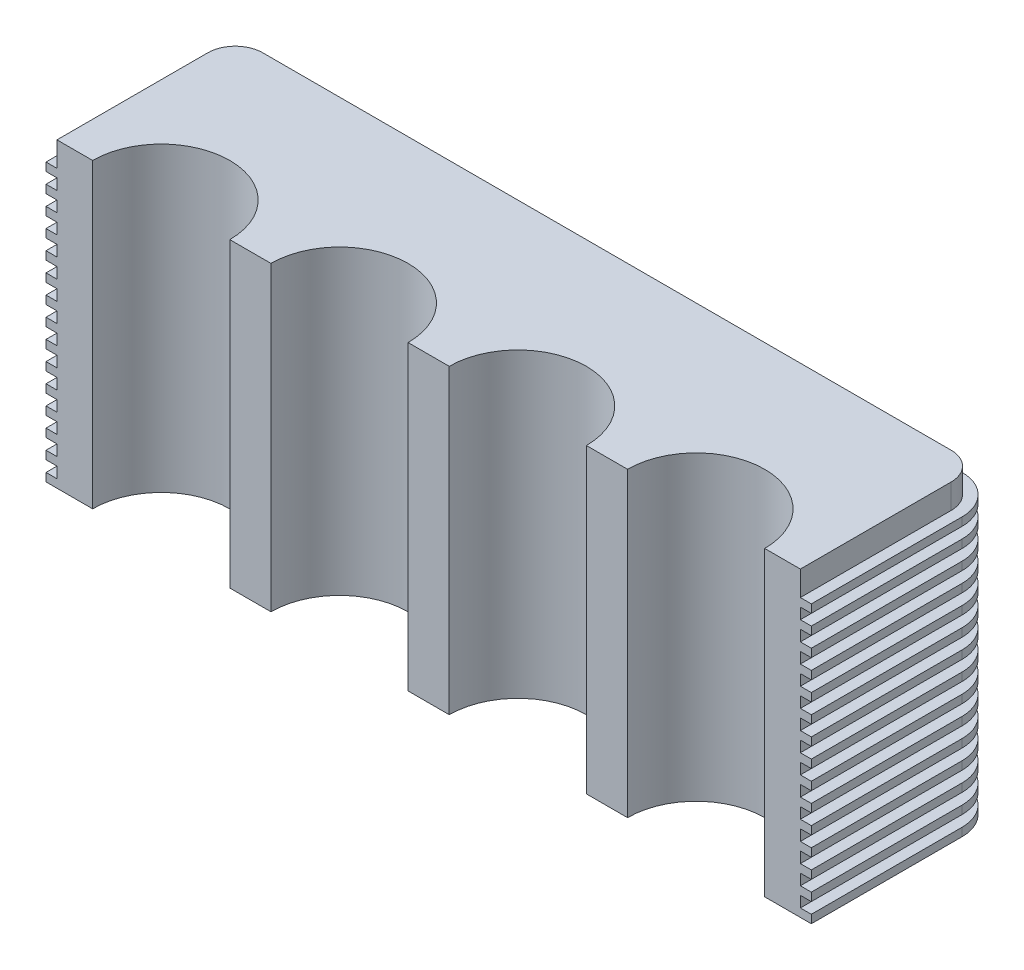
from build123d import *

# Parameters (mm, degrees)
BOSS_EXTRUDE1_DEPTH = 110
BOSS_EXTRUDE2_DEPTH = 3
LPATTERN1_COUNT     = 15
LPATTERN1_PITCH     = 7


with BuildPart() as part:
    # Sketch1 → Boss-Extrude1 (new body)
    with BuildSketch(Plane(origin=(0, 0, 0), x_dir=(1, 0, 0), z_dir=(0, 1, 0))):
        with BuildLine():
            Line((63, 0), (78, 0))
            ThreePointArc((78, 0), (103, 25), (128, 0))
            Line((128, 0), (143, 0))
            ThreePointArc((143, 0), (168, 25), (193, 0))
            Line((193, 0), (208, 0))
            ThreePointArc((208, 0), (233, 25), (258, 0))
            Line((258, 0), (271, 0))
            Line((271, 0), (271, 55))
            ThreePointArc((271, 55), (268.071067812, 62.071067812), (261, 65))
            Line((261, 65), (10, 65))
            ThreePointArc((10, 65), (2.928932188, 62.071067812), (0, 55))
            Line((0, 55), (0, 0))
            Line((0, 0), (13, 0))
            ThreePointArc((13, 0), (38, 25), (63, 0))
        make_face()
    extrude(amount=BOSS_EXTRUDE1_DEPTH)

    # Sketch4 → Boss-Extrude2 (add)
    with BuildSketch(Plane.XZ):
        with BuildLine():
            Line((-4, 0), (-4, -55))
            ThreePointArc((-4, -55), (0.100505063, -64.899494937), (10, -69))
            Line((10, -69), (261, -69))
            ThreePointArc((261, -69), (270.899494937, -64.899494937), (275, -55))
            Line((275, -55), (275, 0))
            Line((275, 0), (271, 0))
            Line((271, 0), (271, -55))
            ThreePointArc((271, -55), (268.071067812, -62.071067812), (261, -65))
            Line((261, -65), (10, -65))
            ThreePointArc((10, -65), (2.928932188, -62.071067812), (0, -55))
            Line((0, -55), (0, 0))
            Line((0, 0), (-4, 0))
        make_face()
    boss_extrude2 = extrude(amount=-BOSS_EXTRUDE2_DEPTH)

    # LPattern1: Boss-Extrude2 ×15
    with Locations(*[(0, i * LPATTERN1_PITCH, 0) for i in range(1, LPATTERN1_COUNT)]):
        add(boss_extrude2)


solid = part.part
